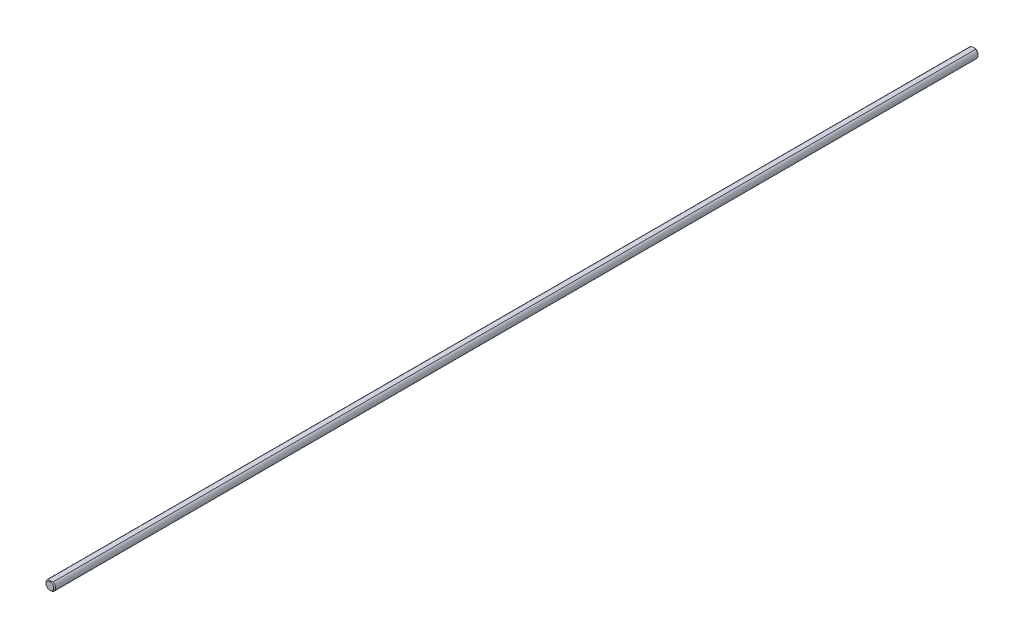
from build123d import *

# Parameters (mm, degrees)
SKETCH1_R           = 3.175
EXTRUDE1_DEPTH      = 304.8
CHAMFER1_SIZE       = 0.635
EXTRUDE7_DEPTH      = 305.8
EXTRUDE7_DEPTH_BACK = 305.8


with BuildPart() as part:
    # Sketch1 → Extrude1 (new body, symmetric)
    with BuildSketch(Plane.XY):
        Circle(SKETCH1_R)
    extrude(amount=EXTRUDE1_DEPTH, both=True)

    # Chamfer1
    chamfer1_edges = [part.edges().sort_by_distance(p)[0] for p in [
        (-3.175, 0, -304.8),
        (-3.175, 0, 304.8),
    ]]
    chamfer(chamfer1_edges, length=CHAMFER1_SIZE)

    # Sketch13 → Extrude7 (cut, two sides)
    with BuildSketch(Plane.XY) as extrude7_sk:
        with BuildLine():
            Line((-1.5875, 2.749630657), (1.5875, 2.749630657))
            ThreePointArc((1.5875, 2.749630657), (0, 3.175), (-1.5875, 2.749630657))
        make_face()
    extrude(amount=EXTRUDE7_DEPTH, mode=Mode.SUBTRACT)
    extrude(extrude7_sk.sketch, amount=-EXTRUDE7_DEPTH_BACK, mode=Mode.SUBTRACT)


solid = part.part
